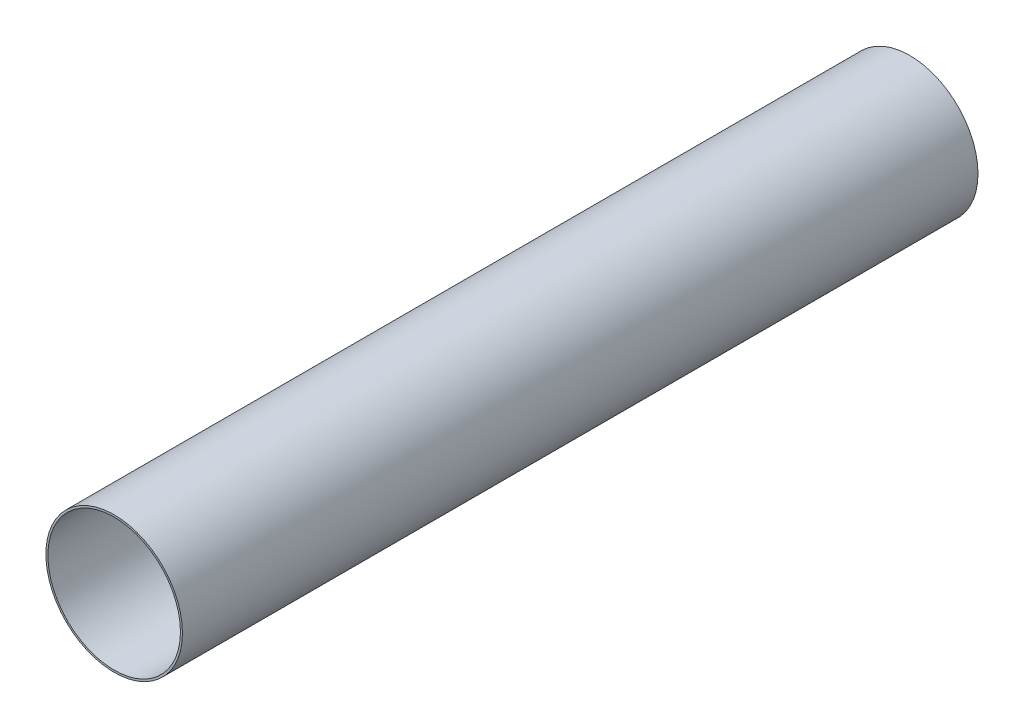
from build123d import *

# Parameters (mm, degrees)
SKETCH1_R           = 65.405
SKETCH1_R_2         = 63.5
BOSS_EXTRUDE1_DEPTH = 381


with BuildPart() as part:
    # Sketch1 → Boss-Extrude1 (new body, symmetric)
    with BuildSketch(Plane.XY):
        Circle(SKETCH1_R)
        Circle(SKETCH1_R_2, mode=Mode.SUBTRACT)
    extrude(amount=BOSS_EXTRUDE1_DEPTH, both=True)


solid = part.part
